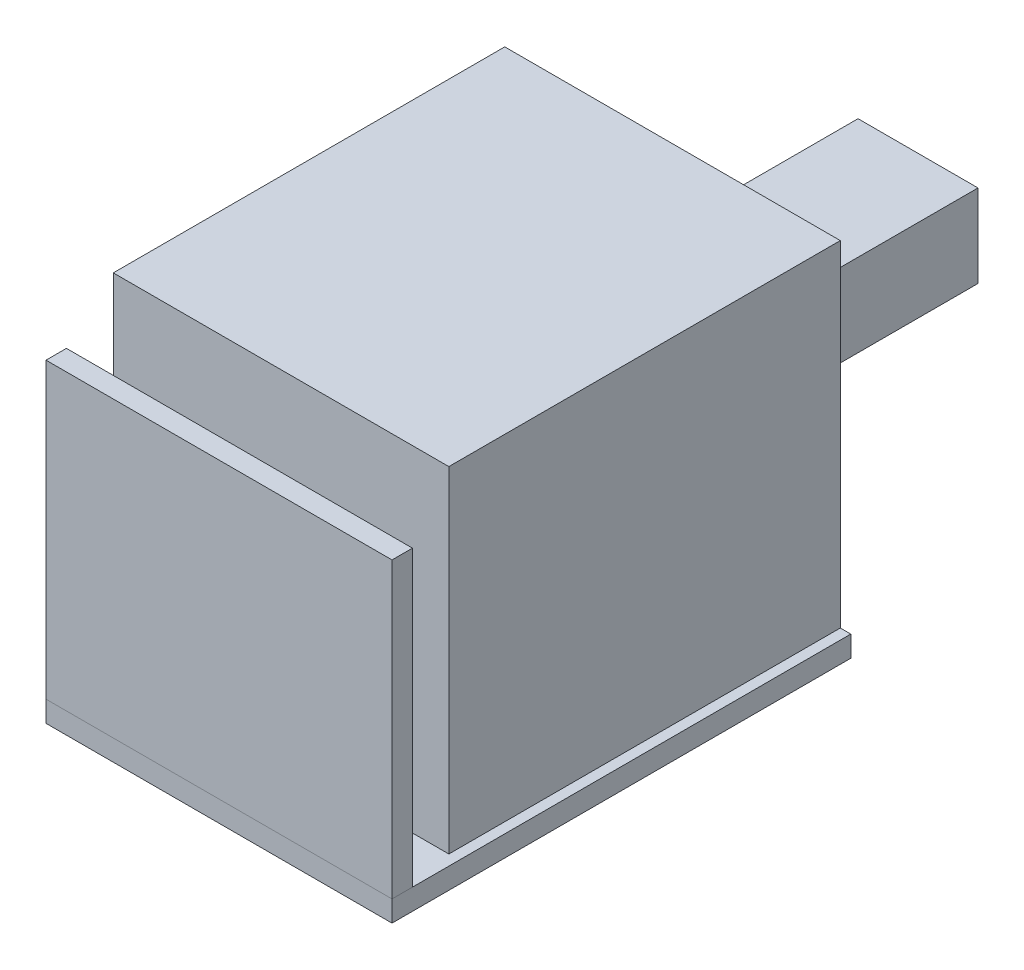
from build123d import *

# Parameters (mm, degrees)
SKETCH1_W        = 14
SKETCH1_H        = 12
BATTERY_DEPTH    = 12
SKETCH2_W        = 4.29
SKETCH2_H        = 2.96
DRIVER_DEPTH     = 6.86
SKETCH10_W       = 12.375
SKETCH10_H       = 16.407214065
PCB_DEPTH        = 0.75
SKETCH11_W       = 8.9
SKETCH11_H       = 12.7
KLR_DEVICE_DEPTH = 2
SKETCH12_W       = 3
SKETCH12_H       = 1.5
ANTENNA_DEPTH    = 0.5
SKETCH13_W       = 12.375
SKETCH13_H       = 0.730661869
SUBSTRATE_DEPTH  = 10.5


with BuildPart() as part:
    # Sketch1 → battery (new body)
    with BuildSketch(Plane(origin=(0, 0, 0), x_dir=(0, 0, -1), z_dir=(1, 0, 0))):
        with Locations((17.087318323, 21.170679999)):
            Rectangle(SKETCH1_W, SKETCH1_H)
    extrude(amount=BATTERY_DEPTH)


with BuildPart() as body_2:
    # Sketch2 → driver (new body)
    with BuildSketch(Plane(origin=(0, 0, -26.007318323), x_dir=(-1, 0, 0), z_dir=(0, 0, -1))):
        with Locations((-6, 21.003531679)):
            Rectangle(SKETCH2_W, SKETCH2_H)
    extrude(amount=DRIVER_DEPTH)


with BuildPart() as body_3:
    # Sketch10 → PCB (new body)
    with BuildSketch(Plane.XZ.offset(-15.170679999)):
        with Locations((6.1875, -15.883711291)):
            Rectangle(SKETCH10_W, SKETCH10_H)
    extrude(amount=PCB_DEPTH)


with BuildPart() as body_4:
    # Sketch11 → KLR device (new body)
    with BuildSketch(Plane.XZ.offset(-14.420679999)):
        with Locations((5.584658381, -17.573378155)):
            Rectangle(SKETCH11_W, SKETCH11_H)
    extrude(amount=KLR_DEVICE_DEPTH)


with BuildPart() as body_5:
    # Sketch12 → antenna (new body)
    with BuildSketch(Plane.XZ.offset(-14.420679999)):
        with Locations((4.544033237, -9.614053485)):
            Rectangle(SKETCH12_W, SKETCH12_H)
    extrude(amount=ANTENNA_DEPTH)


with BuildPart() as body_6:
    # Sketch13 → substrate (new body)
    with BuildSketch(Plane(origin=(0, 15.170679999, 0), x_dir=(1, 0, 0), z_dir=(0, 1, 0))):
        with Locations((6.1875, 8.045435193)):
            Rectangle(SKETCH13_W, SKETCH13_H)
    extrude(amount=SUBSTRATE_DEPTH)


solid = Compound([part.part, body_2.part, body_3.part, body_4.part, body_5.part, body_6.part])
